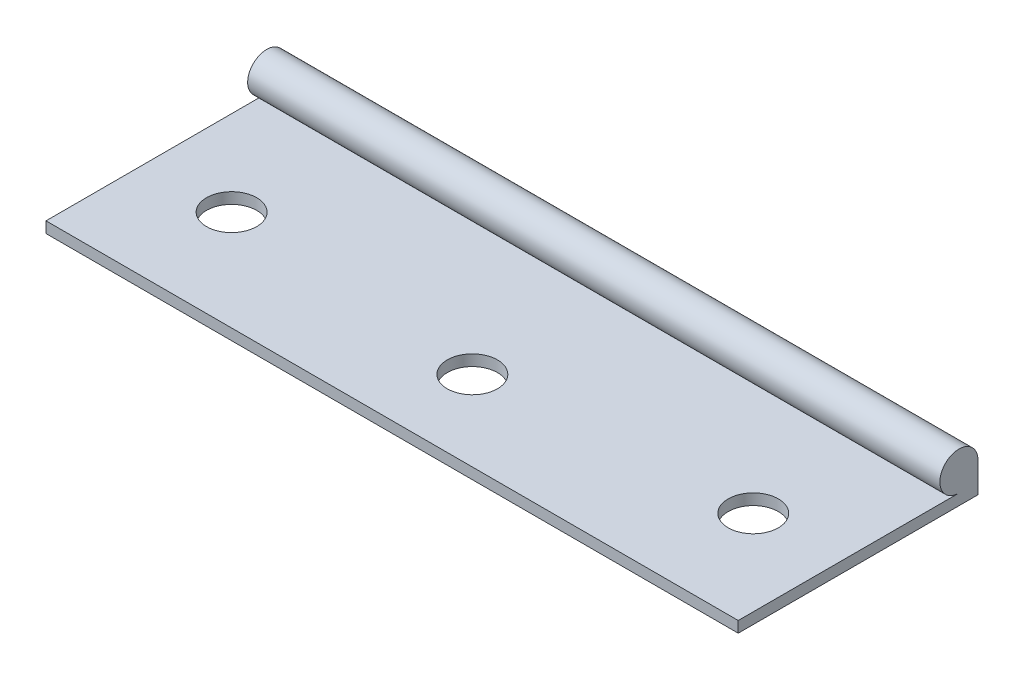
from build123d import *

# Parameters (mm, degrees)
SKETCH_1_R          = 1.9
EXTRUDE_1_DEPTH     = 69
SKETCH_2_R          = 2.5
CUT_EXTRUDE_1_DEPTH = 2.1


with BuildPart() as part:
    # 草图1 → 凸台-拉伸1 (new body)
    with BuildSketch(Plane(origin=(0, 0, 0), x_dir=(0, 0, -1), z_dir=(1, 0, 0))):
        with Locations((22, 3)):
            Circle(SKETCH_1_R)
        with BuildLine():
            Line((0, 1.1), (0, 0))
            Line((0, 0), (19, 0))
            Line((19, 0), (23.9, 0))
            Line((23.9, 0), (23.9, 3))
            ThreePointArc((23.9, 3), (23.343502884, 1.656497116), (22, 1.1))
            Line((22, 1.1), (19, 1.1))
            Line((19, 1.1), (0, 1.1))
        make_face()
    extrude(amount=EXTRUDE_1_DEPTH)

    # 草图2 → 切除-拉伸1 (cut, through all)
    with BuildSketch(Plane(origin=(0, 1.1, 0), x_dir=(1, 0, 0), z_dir=(0, 1, 0))):
        with Locations((8.5, 10)):
            Circle(SKETCH_2_R)
        with Locations((60.5, 10)):
            Circle(SKETCH_2_R)
        with Locations((34.5, 8)):
            Circle(SKETCH_2_R)
    extrude(amount=-CUT_EXTRUDE_1_DEPTH, mode=Mode.SUBTRACT)


solid = part.part
